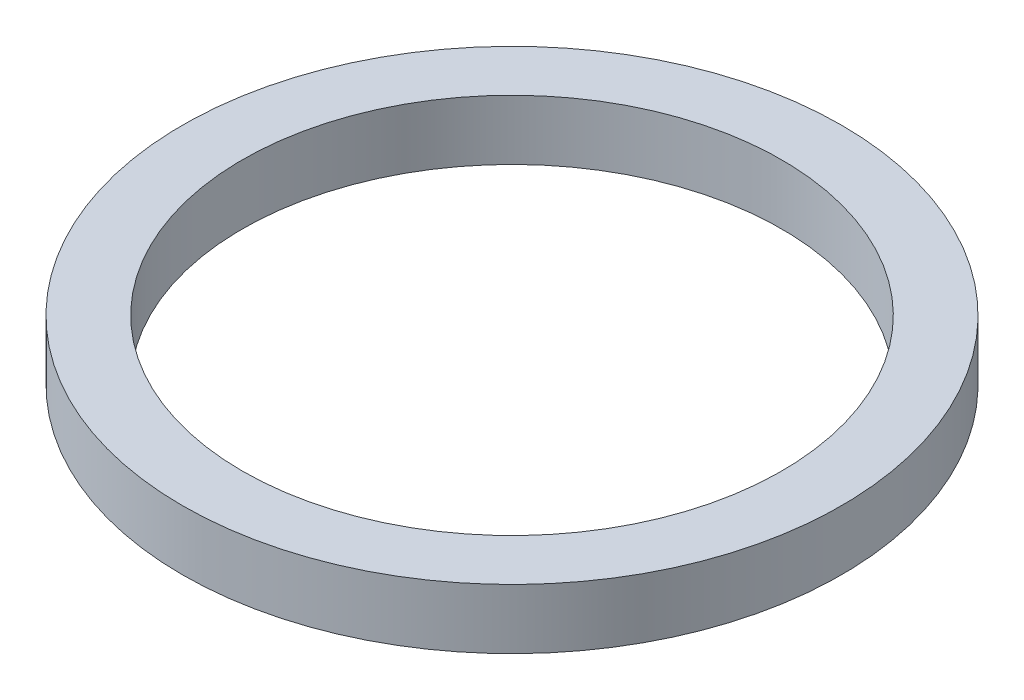
from build123d import *

# Parameters (mm, degrees)
ESQUISSE1_W = 2
ESQUISSE1_H = 2


with BuildPart() as part:
    # Esquisse1 → Révolution1 (revolve)
    with BuildSketch(Plane.XY, mode=Mode.PRIVATE) as r_volution1_sk:
        with Locations((10, 1.720103)):
            Rectangle(ESQUISSE1_W, ESQUISSE1_H)
    revolve(r_volution1_sk.sketch.rotate(Axis((0, 34.132886598, 0), (0, -1, 0)), 90), axis=Axis((0, 34.132886598, 0), (0, -1, 0)))  # turned: the seam where the file's is


solid = part.part
